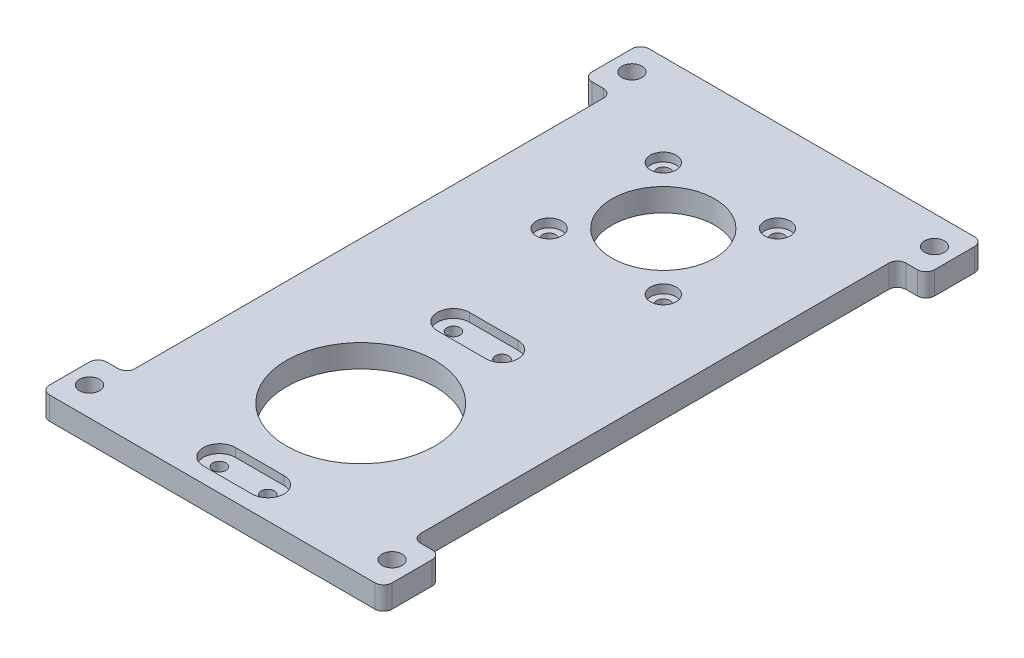
from build123d import *

# Parameters (mm, degrees)
SKETCH_1_W          = 50
SKETCH_1_H          = 105
EXTRUDE_1_DEPTH     = 4
SKETCH_2_R          = 1.15
CUT_EXTRUDE_1_DEPTH = 5
CUT_EXTRUDE_2_DEPTH = 1.5
SKETCH_4_R          = 2.25
CUT_EXTRUDE_3_DEPTH = 1.5
SKETCH_5_R          = 1.15
CUT_EXTRUDE_4_DEPTH = 3.5
SKETCH_6_W          = 5
SKETCH_6_H          = 10
EXTRUDE_2_DEPTH     = 4
SKETCH_7_R          = 1.75
CUT_EXTRUDE_5_DEPTH = 5
SKETCH_8_R          = 13
SKETCH_8_R_2        = 9
CUT_EXTRUDE_6_DEPTH = 5
FILLET_1_R          = 1.5


with BuildPart() as part:
    # 草图1 → 凸台-拉伸1 (new body)
    with BuildSketch(Plane(origin=(0, 0, 0), x_dir=(1, 0, 0), z_dir=(0, 1, 0))):
        with Locations((76.431630633, 94.447783849)):
            Rectangle(SKETCH_1_W, SKETCH_1_H)
    extrude(amount=EXTRUDE_1_DEPTH)

    # 草图2 → 切除-拉伸1 (cut)
    with BuildSketch(Plane(origin=(0, 4, 0), x_dir=(1, 0, 0), z_dir=(0, 1, 0))):
        with Locations((72.181630633, 88.447783849)):
            Circle(SKETCH_2_R)
        with Locations((72.181630633, 47.447783849)):
            Circle(SKETCH_2_R)
        with Locations((80.681630633, 47.447783849)):
            Circle(SKETCH_2_R)
        with Locations((80.681630633, 88.447783849)):
            Circle(SKETCH_2_R)
    extrude(amount=-CUT_EXTRUDE_1_DEPTH, mode=Mode.SUBTRACT)

    # 草图3 → 切除-拉伸2 (cut)
    with BuildSketch(Plane(origin=(0, 4, 0), x_dir=(1, 0, 0), z_dir=(0, 1, 0))):
        with BuildLine():
            Line((72.181630633, 91.247783849), (80.681630633, 91.247783849))
            ThreePointArc((80.681630633, 91.247783849), (83.481630633, 88.447783849), (80.681630633, 85.647783849))
            Line((80.681630633, 85.647783849), (72.181630633, 85.647783849))
            ThreePointArc((72.181630633, 85.647783849), (69.381630633, 88.447783849), (72.181630633, 91.247783849))
        make_face()
        with BuildLine():
            Line((80.681630633, 44.647783849), (72.181630633, 44.647783849))
            ThreePointArc((72.181630633, 44.647783849), (69.381630633, 47.447783849), (72.181630633, 50.247783849))
            Line((72.181630633, 50.247783849), (80.681630633, 50.247783849))
            ThreePointArc((80.681630633, 50.247783849), (83.481630633, 47.447783849), (80.681630633, 44.647783849))
        make_face()
    extrude(amount=-CUT_EXTRUDE_2_DEPTH, mode=Mode.SUBTRACT)

    # 草图4 → 切除-拉伸3 (cut)
    with BuildSketch(Plane(origin=(0, 4, 0), x_dir=(1, 0, 0), z_dir=(0, 1, 0))):
        with Locations((86.431630633, 130.947783849)):
            Circle(SKETCH_4_R)
        with Locations((86.431630633, 110.947783849)):
            Circle(SKETCH_4_R)
        with Locations((66.431630633, 110.947783849)):
            Circle(SKETCH_4_R)
        with Locations((66.431630633, 130.947783849)):
            Circle(SKETCH_4_R)
    extrude(amount=-CUT_EXTRUDE_3_DEPTH, mode=Mode.SUBTRACT)

    # 草图5 → 切除-拉伸4 (cut, through all)
    with BuildSketch(Plane(origin=(0, 2.5, 0), x_dir=(1, 0, 0), z_dir=(0, 1, 0))):
        with Locations((66.431630633, 130.947783849)):
            Circle(SKETCH_5_R)
        with Locations((86.431630633, 130.947783849)):
            Circle(SKETCH_5_R)
        with Locations((66.431630633, 110.947783849)):
            Circle(SKETCH_5_R)
        with Locations((86.431630633, 110.947783849)):
            Circle(SKETCH_5_R)
    extrude(amount=-CUT_EXTRUDE_4_DEPTH, mode=Mode.SUBTRACT)

    # 草图6 → 凸台-拉伸2 (add)
    with BuildSketch(Plane(origin=(0, 4, 0), x_dir=(1, 0, 0), z_dir=(0, 1, 0))):
        with Locations((103.931630633, 46.947783849)):
            Rectangle(SKETCH_6_W, SKETCH_6_H)
        with Locations((48.931630633, 46.947783849)):
            Rectangle(SKETCH_6_W, SKETCH_6_H)
        with Locations((48.931630633, 141.947783849)):
            Rectangle(SKETCH_6_W, SKETCH_6_H)
        with Locations((103.931630633, 141.947783849)):
            Rectangle(SKETCH_6_W, SKETCH_6_H)
    extrude(amount=-EXTRUDE_2_DEPTH)

    # 草图7 → 切除-拉伸5 (cut, through all)
    with BuildSketch(Plane(origin=(0, 4, 0), x_dir=(1, 0, 0), z_dir=(0, 1, 0))):
        with Locations((102.931630633, 46.947783849)):
            Circle(SKETCH_7_R)
        with Locations((49.931630633, 46.947783849)):
            Circle(SKETCH_7_R)
        with Locations((49.931630633, 141.947783849)):
            Circle(SKETCH_7_R)
        with Locations((102.931630633, 141.947783849)):
            Circle(SKETCH_7_R)
    extrude(amount=-CUT_EXTRUDE_5_DEPTH, mode=Mode.SUBTRACT)

    # 草图8 → 切除-拉伸6 (cut, through all)
    with BuildSketch(Plane(origin=(0, 4, 0), x_dir=(1, 0, 0), z_dir=(0, 1, 0))):
        with Locations((76.431630633, 67.947783849)):
            Circle(SKETCH_8_R)
        with Locations((76.431630633, 120.947783849)):
            Circle(SKETCH_8_R_2)
    extrude(amount=-CUT_EXTRUDE_6_DEPTH, mode=Mode.SUBTRACT)

    # 圆角1
    fillet_1_edges = [part.edges().sort_by_distance(p)[0] for p in [
        (106.431630633, 2, -146.947783849),
        (106.431630633, 2, -136.947783849),
        (101.431630633, 2, -136.947783849),
        (51.431630633, 2, -136.947783849),
        (46.431630633, 2, -136.947783849),
        (46.431630633, 2, -146.947783849),
        (51.431630633, 2, -51.947783849),
        (46.431630633, 2, -41.947783849),
        (46.431630633, 2, -51.947783849),
        (106.431630633, 2, -41.947783849),
        (101.431630633, 2, -51.947783849),
        (106.431630633, 2, -51.947783849),
    ]]
    fillet(fillet_1_edges, radius=FILLET_1_R)


solid = part.part
